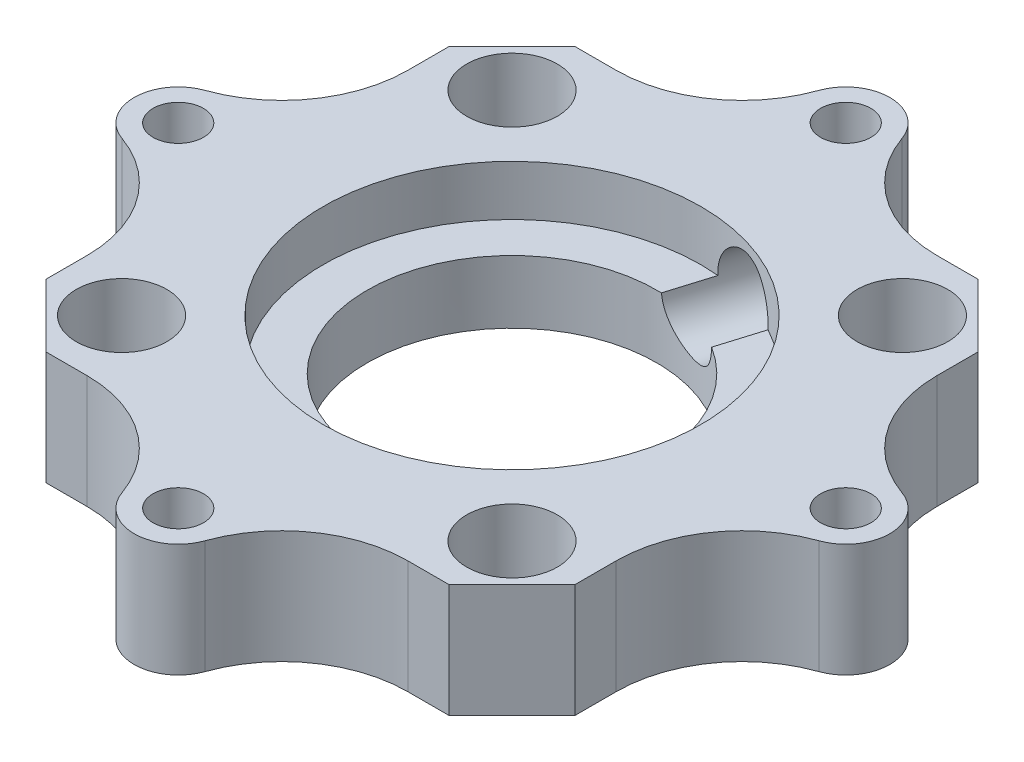
from build123d import *

# Parameters (mm, degrees)
SKETCH1_W               = 60
SKETCH1_H               = 60
SKETCH1_R               = 11.5
BOSS_EXTRUDE1_DEPTH     = 5
CUT_EXTRUDE1_DEPTH      = 10
SKETCH3_R               = 3.6
CUT_EXTRUDE2_DEPTH      = 3
SKETCH4_R               = 1.6
CUT_EXTRUDE3_DEPTH      = 3
SKETCH5_R               = 2
CUT_EXTRUDE4_DEPTH      = 6
CUT_EXTRUDE5_DEPTH      = 6
CHAMFER1_SIZE           = 5
FILLET1_R               = 10
SKETCH7_R               = 2
SKETCH7_R_2             = 3.6
SKETCH7_R_3             = 11.5
BOSS_EXTRUDE2_DEPTH     = 4
SKETCH8_R               = 15
CUT_EXTRUDE6_DEPTH      = 4
SKETCH10_R              = 3
CUT_EXTRUDE7_DEPTH      = 10
CUT_EXTRUDE7_DEPTH_BACK = 16


with BuildPart() as part:
    # Sketch1 → Boss-Extrude1 (new body)
    with BuildSketch(Plane(origin=(0, 0, 0), x_dir=(1, 0, 0), z_dir=(0, 1, 0))):
        Rectangle(SKETCH1_W, SKETCH1_H)
        Circle(SKETCH1_R, mode=Mode.SUBTRACT)
    extrude(amount=BOSS_EXTRUDE1_DEPTH)

    # Sketch2 → Cut-Extrude1 (cut)
    with BuildSketch(Plane(origin=(0, 5, 0), x_dir=(1, 0, 0), z_dir=(0, 1, 0))):
        with BuildLine():
            Line((-30, 30), (-30, 0))
            ThreePointArc((-30, 0), (-21.21320342, 21.213203451), (4.3e-08, 30))
            Line((4.3e-08, 30), (-30, 30))
        make_face()
        with BuildLine():
            ThreePointArc((4.3e-08, 30), (21.213203451, 21.21320342), (30, 0))
            Line((30, 0), (30, 30))
            Line((30, 30), (4.3e-08, 30))
        make_face()
        with BuildLine():
            Line((0, -30), (30, -30))
            Line((30, -30), (30, 0))
            ThreePointArc((30, 0), (21.213203436, -21.213203436), (0, -30))
        make_face()
        with BuildLine():
            Line((-30, -30), (0, -30))
            ThreePointArc((0, -30), (-21.213203436, -21.213203436), (-30, 0))
            Line((-30, 0), (-30, -30))
        make_face()
    extrude(amount=-CUT_EXTRUDE1_DEPTH, mode=Mode.SUBTRACT)

    # Sketch3 → Cut-Extrude2 (cut)
    with BuildSketch(Plane(origin=(0, 5, 0), x_dir=(1, 0, 0), z_dir=(0, 1, 0))):
        with Locations((-15.5, 15.5)):
            Circle(SKETCH3_R)
        with Locations((15.5, 15.5)):
            Circle(SKETCH3_R)
        with Locations((15.5, -15.5)):
            Circle(SKETCH3_R)
        with Locations((-15.5, -15.5)):
            Circle(SKETCH3_R)
    extrude(amount=-CUT_EXTRUDE2_DEPTH, mode=Mode.SUBTRACT)

    # Sketch4 → Cut-Extrude3 (cut)
    with BuildSketch(Plane(origin=(0, 2, 0), x_dir=(1, 0, 0), z_dir=(0, 1, 0))):
        with Locations((-15.5, 15.5)):
            Circle(SKETCH4_R)
        with Locations((15.5, 15.5)):
            Circle(SKETCH4_R)
        with Locations((15.5, -15.5)):
            Circle(SKETCH4_R)
        with Locations((-15.5, -15.5)):
            Circle(SKETCH4_R)
    extrude(amount=-CUT_EXTRUDE3_DEPTH, mode=Mode.SUBTRACT)

    # Sketch5 → Cut-Extrude4 (cut, through all)
    with BuildSketch(Plane(origin=(0, 5, 0), x_dir=(1, 0, 0), z_dir=(0, 1, 0))):
        with Locations((-26.5, 0)):
            Circle(SKETCH5_R)
        with Locations((0, 26.5)):
            Circle(SKETCH5_R)
        with Locations((26.5, 0)):
            Circle(SKETCH5_R)
        with Locations((0, -26.5)):
            Circle(SKETCH5_R)
    extrude(amount=-CUT_EXTRUDE4_DEPTH, mode=Mode.SUBTRACT)

    # Sketch6 → Cut-Extrude5 (cut, through all)
    with BuildSketch(Plane(origin=(0, 5, 0), x_dir=(1, 0, 0), z_dir=(0, 1, 0))):
        with BuildLine():
            ThreePointArc((-3.5, 26.5), (-2.474873736, 28.974873732), (-5e-09, 30))
            ThreePointArc((-5e-09, 30), (-21.213203437, 21.213203434), (-30, 1e-09))
            ThreePointArc((-30, 1e-09), (-28.974873734, 2.474873735), (-26.5, 3.5))
            Line((-26.5, 3.5), (-21, 3.5))
            Line((-21, 3.5), (-21, 21))
            Line((-21, 21), (-3.5, 21))
            Line((-3.5, 21), (-3.5, 26.5))
        make_face()
        with BuildLine():
            Line((3.5, 26.5), (3.5, 21))
            Line((3.5, 21), (21, 21))
            Line((21, 21), (21, 3.5))
            Line((21, 3.5), (26.5, 3.5))
            ThreePointArc((26.5, 3.5), (28.974873734, 2.474873734), (30, 0))
            ThreePointArc((30, 0), (21.213203434, 21.213203438), (-5e-09, 30))
            ThreePointArc((-5e-09, 30), (2.474873732, 28.974873736), (3.5, 26.5))
        make_face()
        with BuildLine():
            ThreePointArc((-26.5, -3.5), (-28.974873735, -2.474873734), (-30, 1e-09))
            ThreePointArc((-30, 1e-09), (-21.213203436, -21.213203435), (0, -30))
            ThreePointArc((0, -30), (-2.474873734, -28.974873734), (-3.5, -26.5))
            Line((-3.5, -26.5), (-3.5, -21))
            Line((-3.5, -21), (-21, -21))
            Line((-21, -21), (-21, -3.5))
            Line((-21, -3.5), (-26.5, -3.5))
        make_face()
        with BuildLine():
            ThreePointArc((0, -30), (21.213203436, -21.213203436), (30, 0))
            ThreePointArc((30, 0), (28.974873734, -2.474873734), (26.5, -3.5))
            Line((26.5, -3.5), (21, -3.5))
            Line((21, -3.5), (21, -21))
            Line((21, -21), (3.5, -21))
            Line((3.5, -21), (3.5, -26.5))
            ThreePointArc((3.5, -26.5), (2.474873734, -28.974873734), (0, -30))
        make_face()
    extrude(amount=-CUT_EXTRUDE5_DEPTH, mode=Mode.SUBTRACT)

    # Chamfer1
    chamfer1_edges = [part.edges().sort_by_distance(p)[0] for p in [
        (21, 2.5, 21),
        (-21, 2.5, -21),
        (-21, 2.5, 21),
        (21, 2.5, -21),
    ]]
    chamfer(chamfer1_edges, length=CHAMFER1_SIZE)

    # Fillet1
    fillet1_edges = [part.edges().sort_by_distance(p)[0] for p in [
        (3.5, 2.5, -21),
        (-3.5, 2.5, -21),
        (-21, 2.5, -3.5),
        (-21, 2.5, 3.5),
        (-3.5, 2.5, 21),
        (3.5, 2.5, 21),
        (21, 2.5, 3.5),
        (21, 2.5, -3.5),
    ]]
    fillet(fillet1_edges, radius=FILLET1_R)

    # Sketch7 → Boss-Extrude2 (add)
    with BuildSketch(Plane(origin=(0, 5, 0), x_dir=(1, 0, 0), z_dir=(0, 1, 0))):
        with BuildLine():
            Line((-21, -12.727922061), (-21, -16))
            Line((-21, -16), (-16, -21))
            Line((-16, -21), (-12.727922061, -21))
            ThreePointArc((-12.727922061, -21), (-6.954419369, -22.835034191), (-3.299831646, -27.666666667))
            ThreePointArc((-3.299831646, -27.666666667), (0, -30), (3.299831646, -27.666666667))
            ThreePointArc((3.299831646, -27.666666667), (6.954419369, -22.835034191), (12.727922061, -21))
            Line((12.727922061, -21), (16, -21))
            Line((16, -21), (21, -16))
            Line((21, -16), (21, -12.727922061))
            ThreePointArc((21, -12.727922061), (22.835034191, -6.954419369), (27.666666667, -3.299831646))
            ThreePointArc((27.666666667, -3.299831646), (30, 0), (27.666666667, 3.299831646))
            ThreePointArc((27.666666667, 3.299831646), (22.835034191, 6.954419369), (21, 12.727922061))
            Line((21, 12.727922061), (21, 16))
            Line((21, 16), (16, 21))
            Line((16, 21), (12.727922061, 21))
            ThreePointArc((12.727922061, 21), (6.954419369, 22.835034191), (3.299831646, 27.666666667))
            ThreePointArc((3.299831646, 27.666666667), (0, 30), (-3.299831646, 27.666666667))
            ThreePointArc((-3.299831646, 27.666666667), (-6.954419369, 22.835034191), (-12.727922061, 21))
            Line((-12.727922061, 21), (-16, 21))
            Line((-16, 21), (-21, 16))
            Line((-21, 16), (-21, 12.727922061))
            ThreePointArc((-21, 12.727922061), (-22.835034191, 6.954419369), (-27.666666667, 3.299831646))
            ThreePointArc((-27.666666667, 3.299831646), (-30, 0), (-27.666666667, -3.299831646))
            ThreePointArc((-27.666666667, -3.299831646), (-22.835034191, -6.954419369), (-21, -12.727922061))
        make_face()
        with Locations((-26.5, 0)):
            Circle(SKETCH7_R, mode=Mode.SUBTRACT)
        with Locations((0, 26.5)):
            Circle(SKETCH7_R, mode=Mode.SUBTRACT)
        with Locations((26.5, 0)):
            Circle(SKETCH7_R, mode=Mode.SUBTRACT)
        with Locations((0, -26.5)):
            Circle(SKETCH7_R, mode=Mode.SUBTRACT)
        with Locations((-15.5, 15.5)):
            Circle(SKETCH7_R_2, mode=Mode.SUBTRACT)
        with Locations((15.5, 15.5)):
            Circle(SKETCH7_R_2, mode=Mode.SUBTRACT)
        with Locations((15.5, -15.5)):
            Circle(SKETCH7_R_2, mode=Mode.SUBTRACT)
        with Locations((-15.5, -15.5)):
            Circle(SKETCH7_R_2, mode=Mode.SUBTRACT)
        Circle(SKETCH7_R_3, mode=Mode.SUBTRACT)
    extrude(amount=BOSS_EXTRUDE2_DEPTH)

    # Sketch8 → Cut-Extrude6 (cut)
    with BuildSketch(Plane(origin=(0, 9, 0), x_dir=(1, 0, 0), z_dir=(0, 1, 0))):
        Circle(SKETCH8_R)
    extrude(amount=-CUT_EXTRUDE6_DEPTH, mode=Mode.SUBTRACT)

    # Sketch10 → Cut-Extrude7 (cut, two sides)
    with BuildSketch(Plane(origin=(6.806656618, 0, -22.349850985), x_dir=(-0.956619879, 0, -0.291338991), z_dir=(0.291338991, 0, -0.956619879))) as cut_extrude7_sk:
        with Locations((0, 5.23531916)):
            Circle(SKETCH10_R)
    extrude(amount=CUT_EXTRUDE7_DEPTH, mode=Mode.SUBTRACT)
    extrude(cut_extrude7_sk.sketch, amount=-CUT_EXTRUDE7_DEPTH_BACK, mode=Mode.SUBTRACT)


solid = part.part
